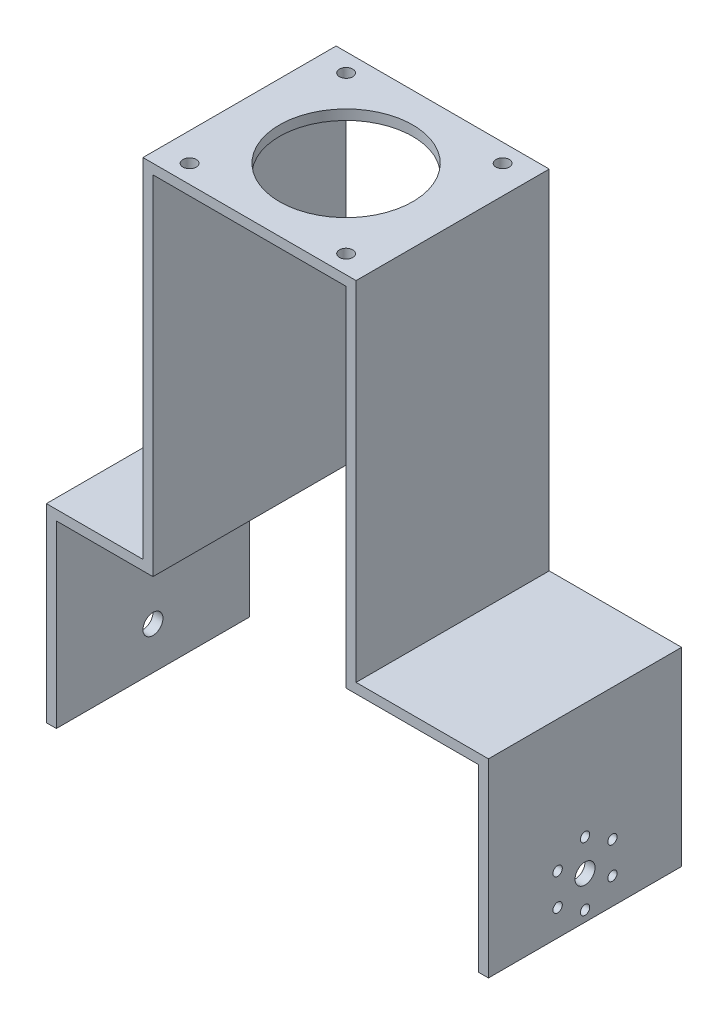
from build123d import *

# Parameters (mm, degrees)
BOSS_EXTRUDE1_DEPTH = 58
SKETCH3_R           = 2
SKETCH3_R_2         = 20
CUT_EXTRUDE1_DEPTH  = 58
SKETCH4_R           = 3
SKETCH4_R_2         = 1.4
CUT_EXTRUDE2_DEPTH  = 58
SKETCH5_R           = 3
CUT_EXTRUDE3_DEPTH  = 58


with BuildPart() as part:
    # Sketch2 → Boss-Extrude1 (new body)
    with BuildSketch(Plane.XY):
        Polygon((0, 51.896715462), (32, 51.896715462), (32, -52.603284538), (71.75, -52.603284538), (71.75, -109.603284538), (68.75, -109.603284538), (68.75, -55.603284538), (29, -55.603284538), (29, 48.896715462), (0, 48.896715462), (-29, 48.896715462), (-29, -55.603284538), (-58, -55.603284538), (-58, -109.603284538), (-61, -109.603284538), (-61, -52.603284538), (-32, -52.603284538), (-32, 51.896715462), align=None)
    extrude(amount=BOSS_EXTRUDE1_DEPTH)

    # Sketch3 → Cut-Extrude1 (cut)
    with BuildSketch(Plane(origin=(0, 51.896715462, 0), x_dir=(1, 0, 0), z_dir=(0, 1, 0))):
        with Locations((-23.5, -5.5)):
            Circle(SKETCH3_R)
        with Locations((23.5, -5.5)):
            Circle(SKETCH3_R)
        with Locations((23.5, -52.5)):
            Circle(SKETCH3_R)
        with Locations((-23.5, -52.5)):
            Circle(SKETCH3_R)
        with Locations((0, -29)):
            Circle(SKETCH3_R_2)
    extrude(amount=-CUT_EXTRUDE1_DEPTH, mode=Mode.SUBTRACT)

    # Sketch4 → Cut-Extrude2 (cut)
    with BuildSketch(Plane(origin=(71.75, 0, 0), x_dir=(0, 0, -1), z_dir=(1, 0, 0))):
        with Locations((-29, -96.903284538)):
            Circle(SKETCH4_R)
        with Locations((-29, -87.403284538)):
            Circle(SKETCH4_R_2)
        with Locations((-20.772758664, -92.153284538)):
            Circle(SKETCH4_R_2)
        with Locations((-20.772758664, -101.653284538)):
            Circle(SKETCH4_R_2)
        with Locations((-29, -106.403284538)):
            Circle(SKETCH4_R_2)
        with Locations((-37.227241336, -101.653284538)):
            Circle(SKETCH4_R_2)
        with Locations((-37.227241336, -92.153284538)):
            Circle(SKETCH4_R_2)
    extrude(amount=-CUT_EXTRUDE2_DEPTH, mode=Mode.SUBTRACT)

    # Sketch5 → Cut-Extrude3 (cut)
    with BuildSketch(Plane.ZY.offset(61)):
        with Locations((29, -96.903284538)):
            Circle(SKETCH5_R)
    extrude(amount=-CUT_EXTRUDE3_DEPTH, mode=Mode.SUBTRACT)


solid = part.part
